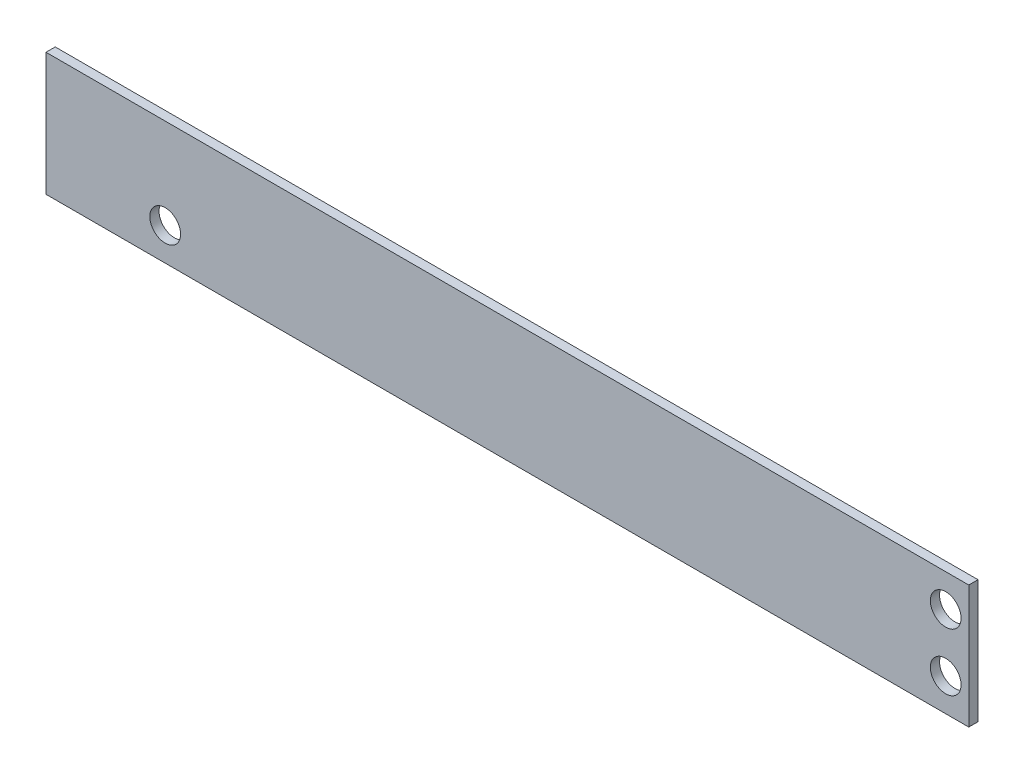
from build123d import *

# Parameters (mm, degrees)
SKETCH2_W   = 60
SKETCH2_H   = 8
SKETCH2_R   = 1
BOARD_DEPTH = 0.6


with BuildPart() as part:
    # Sketch2 → board (new body)
    with BuildSketch(Plane.XY):
        with Locations((2.5, 0)):
            Rectangle(SKETCH2_W, SKETCH2_H)
        with Locations((-19.75, -1.875)):
            Circle(SKETCH2_R, mode=Mode.SUBTRACT)
        with Locations((31, 1.875)):
            Circle(SKETCH2_R, mode=Mode.SUBTRACT)
        with Locations((31, -1.875)):
            Circle(SKETCH2_R, mode=Mode.SUBTRACT)
    extrude(amount=BOARD_DEPTH)


solid = part.part
